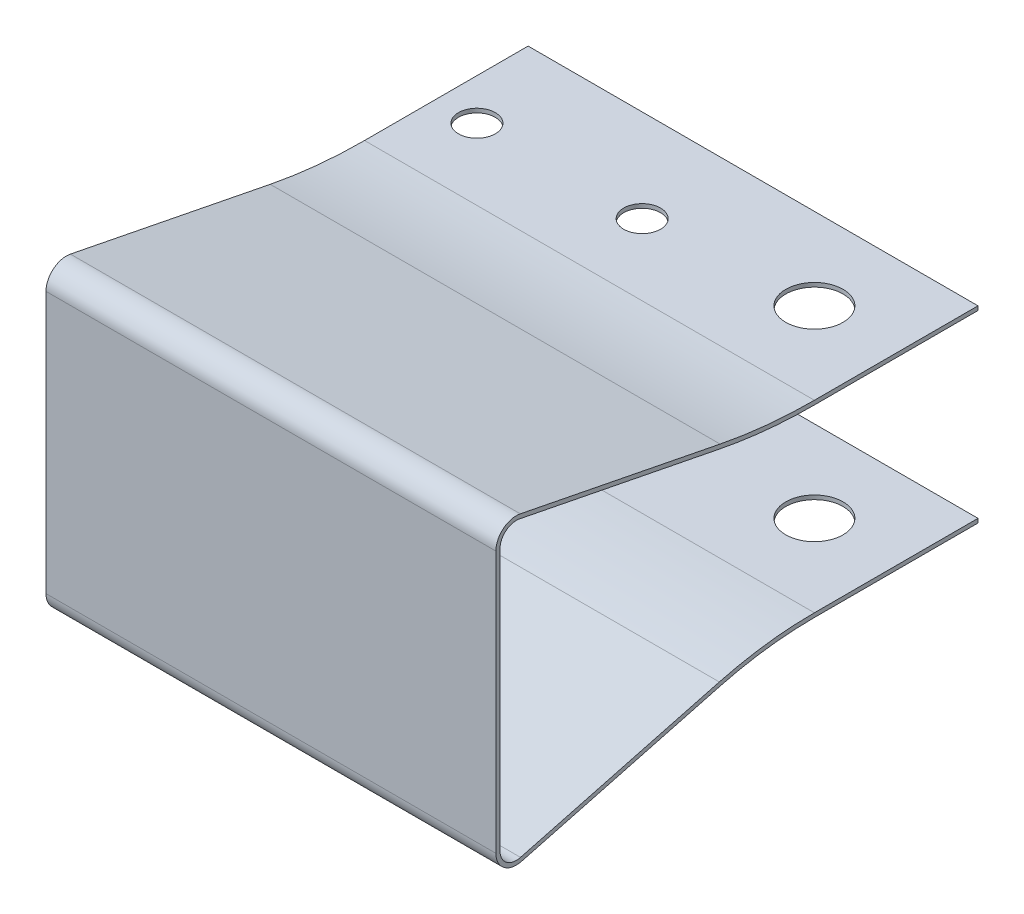
from build123d import *

# Parameters (mm, degrees)
EXTRUDE1_DEPTH          = 13.75
SKETCH2_R               = 1.75
SKETCH2_R_2             = 1.125
CUT_EXTRUDE1_DEPTH      = 10.25
CUT_EXTRUDE1_DEPTH_BACK = 10.25


with BuildPart() as part:
    # Sketch1 → Extrude1 (new body, symmetric)
    with BuildSketch(Plane(origin=(0, 0, 0), x_dir=(0, 0, -1), z_dir=(1, 0, 0))):
        with BuildLine():
            Line((-24.22, 8), (-24.22, -8))
            ThreePointArc((-24.22, -8), (-23.830111825, -8.792315317), (-22.964472878, -8.966801888))
            Line((-22.964472878, -8.966801888), (-10.813561051, -5.755298505))
            ThreePointArc((-10.813561051, -5.755298505), (-7.931209986, -5.189614776), (-5, -5))
            Line((-5, -5), (5, -5))
            Line((5, -5), (5, -5.25))
            Line((5, -5.25), (-5, -5.25))
            ThreePointArc((-5, -5.25), (-7.899000655, -5.437531211), (-10.749679271, -5.996998977))
            Line((-10.749679271, -5.996998977), (-22.900591097, -9.208502359))
            ThreePointArc((-22.900591097, -9.208502359), (-23.982639781, -8.990394146), (-24.47, -8))
            Line((-24.47, -8), (-24.47, 8))
            ThreePointArc((-24.47, 8), (-24.013634161, 8.965735377), (-22.97776829, 9.226304937))
            Line((-22.97776829, 9.226304937), (-10.765114709, 6.8139425))
            ThreePointArc((-10.765114709, 6.8139425), (-7.896315709, 6.391321284), (-5, 6.25))
            Line((-5, 6.25), (5, 6.25))
            Line((5, 6.25), (5, 6))
            Line((5, 6), (-5, 6))
            ThreePointArc((-5, 6), (-7.920654497, 6.142508858), (-10.813561051, 6.568681513))
            Line((-10.813561051, 6.568681513), (-23.026214632, 8.98104395))
            ThreePointArc((-23.026214632, 8.98104395), (-23.854907329, 8.772588302), (-24.22, 8))
        make_face()
    extrude(amount=EXTRUDE1_DEPTH, both=True)

    # Sketch2 → Cut-Extrude1 (cut, two sides)
    with BuildSketch(Plane(origin=(0, 0, 0), x_dir=(1, 0, 0), z_dir=(0, 1, 0))) as cut_extrude1_sk:
        with Locations(Location((8.75, 0, 0), (0, 0, 270))):  # turned: the seam where the file's is
            Circle(SKETCH2_R)
        with Locations(Location((-1.13, -0.65, 0), (0, 0, 270))):  # turned: the seam where the file's is
            Circle(SKETCH2_R_2)
        with Locations(Location((-11.23, -0.65, 0), (0, 0, 270))):  # turned: the seam where the file's is
            Circle(SKETCH2_R_2)
    extrude(amount=CUT_EXTRUDE1_DEPTH, mode=Mode.SUBTRACT)
    extrude(cut_extrude1_sk.sketch, amount=-CUT_EXTRUDE1_DEPTH_BACK, mode=Mode.SUBTRACT)


solid = part.part
